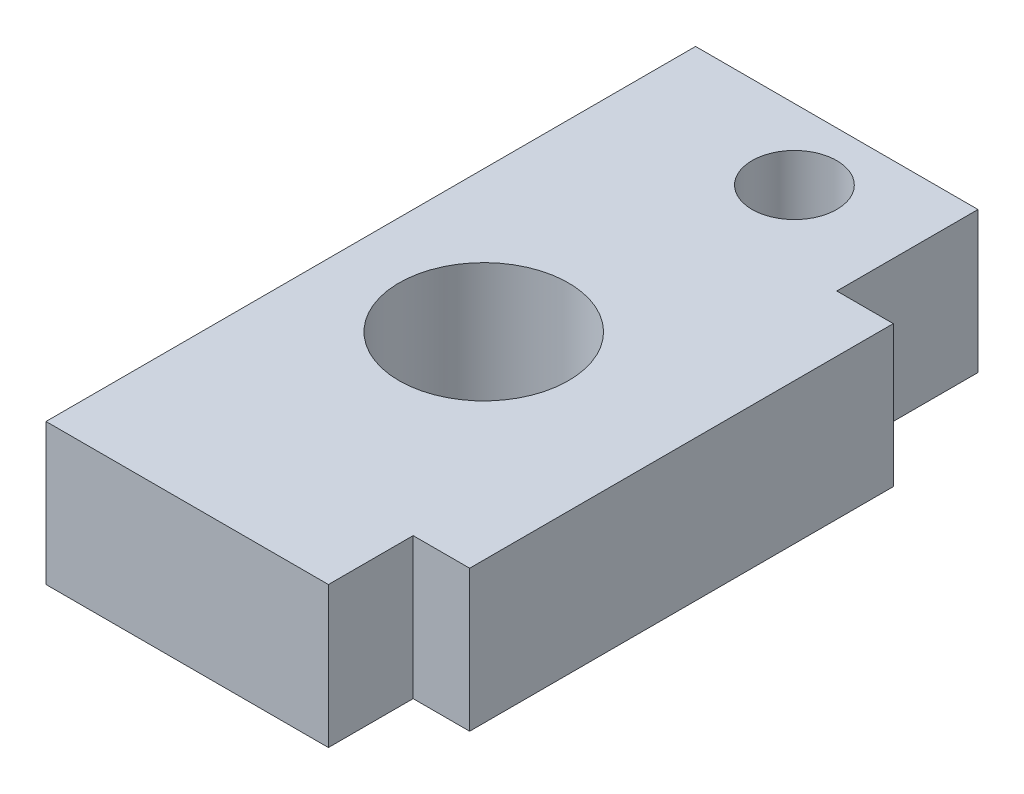
from build123d import *

# Parameters (mm, degrees)
ESQUISSE1_W             = 12
ESQUISSE1_H             = 15
BOSS_EXTRU_1_DEPTH      = 5
ESQUISSE2_W             = 10
ESQUISSE2_H             = 5
ESQUISSE2_H_2           = 3
BOSS_EXTRU_2_DEPTH      = 5
ESQUISSE3_R             = 1.5
ENL_V_MAT_EXTRU_1_DEPTH = 5
ESQUISSE4_R             = 3
ENL_V_MAT_EXTRU_2_DEPTH = 10


with BuildPart() as part:
    # Esquisse1 → Boss.-Extru.1 (new body)
    with BuildSketch(Plane(origin=(0, 0, 0), x_dir=(1, 0, 0), z_dir=(0, 1, 0))):
        with Locations((1, 0)):
            Rectangle(ESQUISSE1_W, ESQUISSE1_H)
    extrude(amount=BOSS_EXTRU_1_DEPTH)

    # Esquisse2 → Boss.-Extru.2 (add)
    with BuildSketch(Plane(origin=(0, 5, 0), x_dir=(1, 0, 0), z_dir=(0, 1, 0))):
        with Locations((0, 10)):
            Rectangle(ESQUISSE2_W, ESQUISSE2_H)
        with Locations((0, -9)):
            Rectangle(ESQUISSE2_W, ESQUISSE2_H_2)
    extrude(amount=-BOSS_EXTRU_2_DEPTH)

    # Esquisse3 → Enlèv. mat.-Extru.1 (cut)
    with BuildSketch(Plane(origin=(0, 5, 0), x_dir=(1, 0, 0), z_dir=(0, 1, 0))):
        with Locations((1, 10)):
            Circle(ESQUISSE3_R)
    extrude(amount=-ENL_V_MAT_EXTRU_1_DEPTH, mode=Mode.SUBTRACT)

    # Esquisse4 → Enlèv. mat.-Extru.2 (cut)
    with BuildSketch(Plane(origin=(0, 5, 0), x_dir=(1, 0, 0), z_dir=(0, 1, 0))):
        Circle(ESQUISSE4_R)
    extrude(amount=-ENL_V_MAT_EXTRU_2_DEPTH, mode=Mode.SUBTRACT)


solid = part.part
